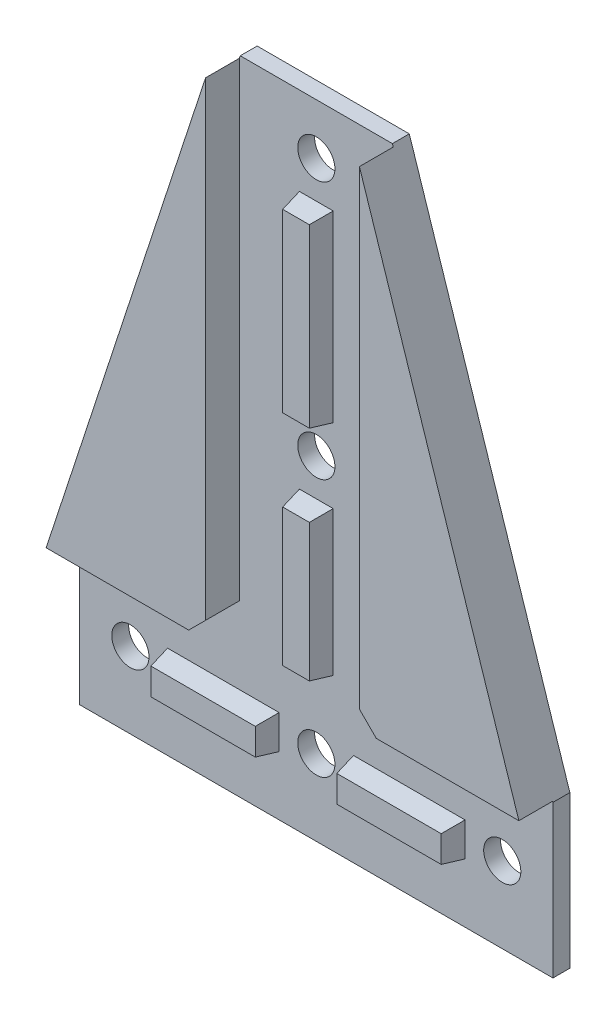
from build123d import *

# Parameters (mm, degrees)
ESQUISSE1_R        = 5.5
BOSS_EXTRU_1_DEPTH = 5
ESQUISSE3_W        = 10
ESQUISSE3_H        = 54.25
ESQUISSE3_H_2      = 42.75
ESQUISSE3_W_2      = 33
ESQUISSE3_H_3      = 10
BOSS_EXTRU_3_DEPTH = 6
D_POUILLE2_ANGLE   = 10
BOSS_EXTRU_4_DEPTH = 10
CHANFREIN1_SIZE    = 5


with BuildPart() as part:
    # Esquisse1 → Boss.-Extru.1 (new body)
    with BuildSketch(Plane.XY):
        Polygon((-22.5, 135.232443508), (22.5, 135.232443508), (70, -9.767556492), (70, -54.767556492), (-70, -54.767556492), (-70, -9.767556492), align=None)
        with Locations((0, 120.232443508)):
            Circle(ESQUISSE1_R, mode=Mode.SUBTRACT)
        with Locations((0, 43.982443508)):
            Circle(ESQUISSE1_R, mode=Mode.SUBTRACT)
        with Locations((0, -32.267556492)):
            Circle(ESQUISSE1_R, mode=Mode.SUBTRACT)
        with Locations((-55, -32.267556492)):
            Circle(ESQUISSE1_R, mode=Mode.SUBTRACT)
        with Locations((55, -32.267556492)):
            Circle(ESQUISSE1_R, mode=Mode.SUBTRACT)
    extrude(amount=BOSS_EXTRU_1_DEPTH)

    # Esquisse3 → Boss.-Extru.3 (add)
    with BuildSketch(Plane.XY.offset(5)):
        with Locations((0, 82.107443508)):
            Rectangle(ESQUISSE3_W, ESQUISSE3_H)
        with Locations((0, 11.607443508)):
            Rectangle(ESQUISSE3_W, ESQUISSE3_H_2)
        with Locations((-27.5, -32.267556492)):
            Rectangle(ESQUISSE3_W_2, ESQUISSE3_H_3)
        with Locations((27.5, -32.267556492)):
            Rectangle(ESQUISSE3_W_2, ESQUISSE3_H_3)
    extrude(amount=BOSS_EXTRU_3_DEPTH)

    # Dépouille2
    d_pouille2_faces = [part.faces().sort_by_distance(p)[0] for p in [
        (0, 32.982443508, 8),
        (-27.5, -27.267556492, 8),
        (27.5, -27.267556492, 8),
        (0, 109.232443508, 8),
        (-11, -32.267556492, 8),
        (44, -32.267556492, 8),
        (5, 82.107443508, 8),
        (5, 11.607443508, 8),
        (-5, 82.107443508, 8),
        (0, 54.982443508, 8),
        (-5, 11.607443508, 8),
        (11, -32.267556492, 8),
        (27.5, -37.267556492, 8),
        (0, -9.767556492, 8),
        (-44, -32.267556492, 8),
        (-27.5, -37.267556492, 8),
    ]]
    draft(d_pouille2_faces, Plane.XY.offset(5), D_POUILLE2_ANGLE)

    # Esquisse4 → Boss.-Extru.4 (add)
    with BuildSketch(Plane.XY.offset(5)):
        Polygon((-22.75, 134.469285613), (-22.75, -9.517556492), (-69.918103448, -9.517556492), align=None)
        Polygon((22.75, -9.517556492), (69.918103448, -9.517556492), (22.75, 134.469285613), align=None)
    extrude(amount=BOSS_EXTRU_4_DEPTH)

    # Chanfrein1
    chanfrein1_edges = [part.edges().sort_by_distance(p)[0] for p in [
        (-22.75, -9.517556492, 10),
        (22.75, -9.517556492, 10),
    ]]
    chamfer(chanfrein1_edges, length=CHANFREIN1_SIZE)


solid = part.part
